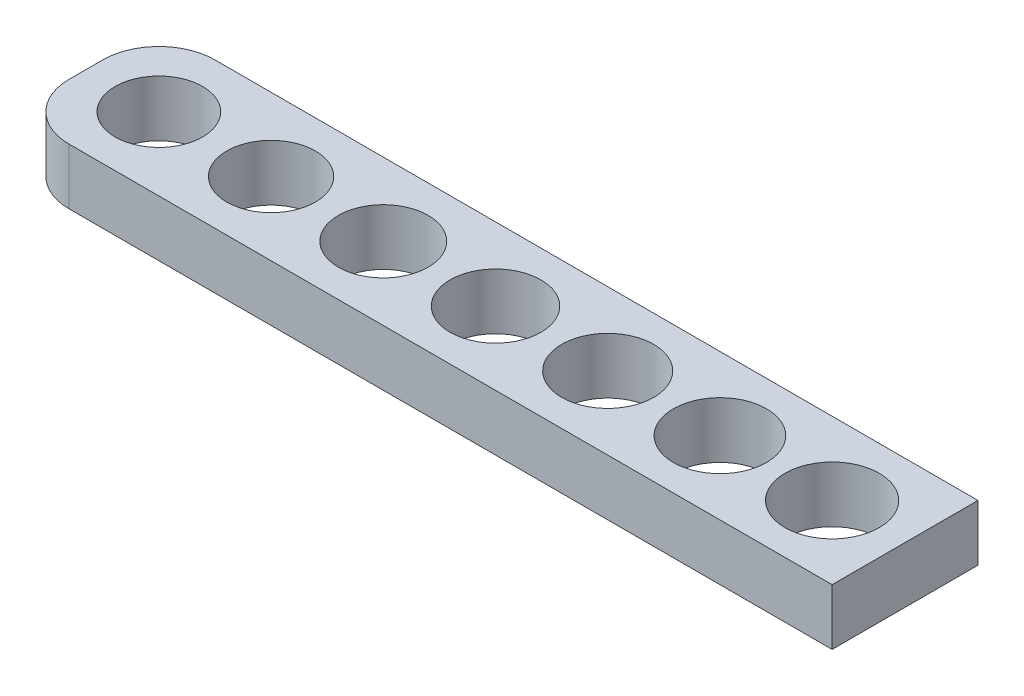
from build123d import *

# Parameters (mm, degrees)
SKETCH2_W           = 73
SKETCH2_H           = 13
SKETCH2_R           = 3.9
SKETCH2_R_2         = 3.95
SKETCH2_R_3         = 4
SKETCH2_R_4         = 4.05
SKETCH2_R_5         = 4.1
SKETCH2_R_6         = 4.15
SKETCH2_R_7         = 4.2
BOSS_EXTRUDE1_DEPTH = 5
FILLET1_R           = 5


with BuildPart() as part:
    # Sketch2 → Boss-Extrude1 (new body)
    with BuildSketch(Plane(origin=(0, 0, 0), x_dir=(1, 0, 0), z_dir=(0, 1, 0))):
        with Locations((30, 0)):
            Rectangle(SKETCH2_W, SKETCH2_H)
        Circle(SKETCH2_R, mode=Mode.SUBTRACT)
        with Locations((10, 0)):
            Circle(SKETCH2_R_2, mode=Mode.SUBTRACT)
        with Locations((20, 0)):
            Circle(SKETCH2_R_3, mode=Mode.SUBTRACT)
        with Locations((30, 0)):
            Circle(SKETCH2_R_4, mode=Mode.SUBTRACT)
        with Locations((40, 0)):
            Circle(SKETCH2_R_5, mode=Mode.SUBTRACT)
        with Locations((50, 0)):
            Circle(SKETCH2_R_6, mode=Mode.SUBTRACT)
        with Locations((60, 0)):
            Circle(SKETCH2_R_7, mode=Mode.SUBTRACT)
    extrude(amount=BOSS_EXTRUDE1_DEPTH)

    # Fillet1
    fillet1_edges = [part.edges().sort_by_distance(p)[0] for p in [
        (-6.5, 2.5, -6.5),
        (-6.5, 2.5, 6.5),
    ]]
    fillet(fillet1_edges, radius=FILLET1_R)


solid = part.part
